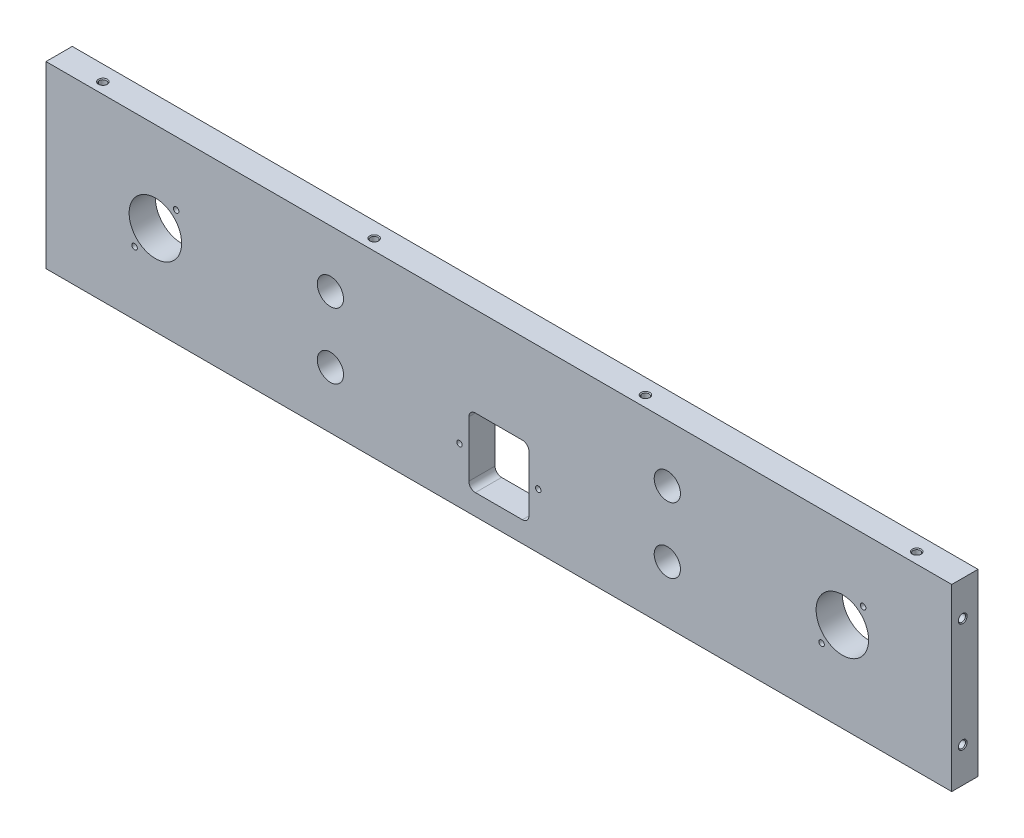
from build123d import *

# Parameters (mm, degrees)
SKETCH_1_W                   = 414
SKETCH_1_H                   = 82
EXTRUDE_1_DEPTH              = 12
SKETCH_2_R                   = 6
SKETCH_2_R_2                 = 12
SKETCH_2_W                   = 27.5
SKETCH_2_H                   = 31.5
CUT_EXTRUDE_5_DEPTH          = 13
FILLET_1_R                   = 3
HOLE_WIZARD_M3_1_D           = 2.5
HOLE_WIZARD_M3_1_CSINK_D     = 3.05
HOLE_WIZARD_M3_1_CSINK_ANGLE = 90
HOLE_WIZARD_M4_1_D           = 3.3
HOLE_WIZARD_M4_1_CSINK_D     = 4.05
HOLE_WIZARD_M4_1_CSINK_ANGLE = 90
HOLE_WIZARD_M4_3_D           = 3.3
HOLE_WIZARD_M4_3_DEPTH       = 7.1
HOLE_WIZARD_M4_3_CSINK_D     = 4.05
HOLE_WIZARD_M4_3_CSINK_ANGLE = 90
HOLE_WIZARD_M4_3_TIP         = 0.991420021
HOLE_WIZARD_M4_4_D           = 3.3
HOLE_WIZARD_M4_4_DEPTH       = 7.1
HOLE_WIZARD_M4_4_CSINK_D     = 4.05
HOLE_WIZARD_M4_4_CSINK_ANGLE = 90
HOLE_WIZARD_M4_4_TIP         = 0.991420021


with BuildPart() as part:
    # 草圖1 → 填料-伸長1 (new body)
    with BuildSketch(Plane.XY):
        with Locations((207, 41)):
            Rectangle(SKETCH_1_W, SKETCH_1_H)
    extrude(amount=EXTRUDE_1_DEPTH)

    # 草圖2 → 除料-伸長5 (cut, through all)
    with BuildSketch(Plane.XY):
        with Locations((130, 56)):
            Circle(SKETCH_2_R)
        with Locations((130, 26)):
            Circle(SKETCH_2_R)
        with Locations((284, 56)):
            Circle(SKETCH_2_R)
        with Locations((284, 26)):
            Circle(SKETCH_2_R)
        with Locations((50, 41)):
            Circle(SKETCH_2_R_2)
        with Locations((364, 41)):
            Circle(SKETCH_2_R_2)
        with Locations((207, 25.25)):
            Rectangle(SKETCH_2_W, SKETCH_2_H)
    extrude(amount=CUT_EXTRUDE_5_DEPTH, mode=Mode.SUBTRACT)

    # 圓角1
    fillet_1_edges = [part.edges().sort_by_distance(p)[0] for p in [
        (220.75, 9.5, 6),
        (220.75, 41, 6),
        (193.25, 41, 6),
        (193.25, 9.5, 6),
    ]]
    fillet(fillet_1_edges, radius=FILLET_1_R)

    # M3 螺紋孔1 (through all)
    with Locations(Plane(origin=(0, 0, 0), x_dir=(1, 0, 0), z_dir=(0, 0, -1))):
        with Locations((59.5, -53), (40.5, -29), (189, -25.25), (225, -25.25), (373.5, -53), (354.5, -29)):
            CounterSinkHole(HOLE_WIZARD_M3_1_D / 2, HOLE_WIZARD_M3_1_CSINK_D / 2, counter_sink_angle=HOLE_WIZARD_M3_1_CSINK_ANGLE)

    # M4 螺紋孔1 (through all)
    with Locations(Plane(origin=(0, 82, 0), x_dir=(1, 0, 0), z_dir=(0, 1, 0))):
        with Locations((21, -7), (145, -7), (269, -7), (393, -7)):
            CounterSinkHole(HOLE_WIZARD_M4_1_D / 2, HOLE_WIZARD_M4_1_CSINK_D / 2, counter_sink_angle=HOLE_WIZARD_M4_1_CSINK_ANGLE)

    # M4 螺紋孔3
    with Locations(Plane(origin=(414, 0, 0), x_dir=(0, 0, -1), z_dir=(1, 0, 0))):
        with Locations((-7, 16), (-7, 66)):
            CounterSinkHole(HOLE_WIZARD_M4_3_D / 2, HOLE_WIZARD_M4_3_CSINK_D / 2, depth=HOLE_WIZARD_M4_3_DEPTH, counter_sink_angle=HOLE_WIZARD_M4_3_CSINK_ANGLE)
            with Locations((0, 0, -(HOLE_WIZARD_M4_3_DEPTH + HOLE_WIZARD_M4_3_TIP / 2))):  # 118° drill point
                Cone(0, HOLE_WIZARD_M4_3_D / 2, HOLE_WIZARD_M4_3_TIP, mode=Mode.SUBTRACT)

    # M4 螺紋孔4
    with Locations(Plane.ZY):
        with Locations((7, 16), (7, 66)):
            CounterSinkHole(HOLE_WIZARD_M4_4_D / 2, HOLE_WIZARD_M4_4_CSINK_D / 2, depth=HOLE_WIZARD_M4_4_DEPTH, counter_sink_angle=HOLE_WIZARD_M4_4_CSINK_ANGLE)
            with Locations((0, 0, -(HOLE_WIZARD_M4_4_DEPTH + HOLE_WIZARD_M4_4_TIP / 2))):  # 118° drill point
                Cone(0, HOLE_WIZARD_M4_4_D / 2, HOLE_WIZARD_M4_4_TIP, mode=Mode.SUBTRACT)


solid = part.part
